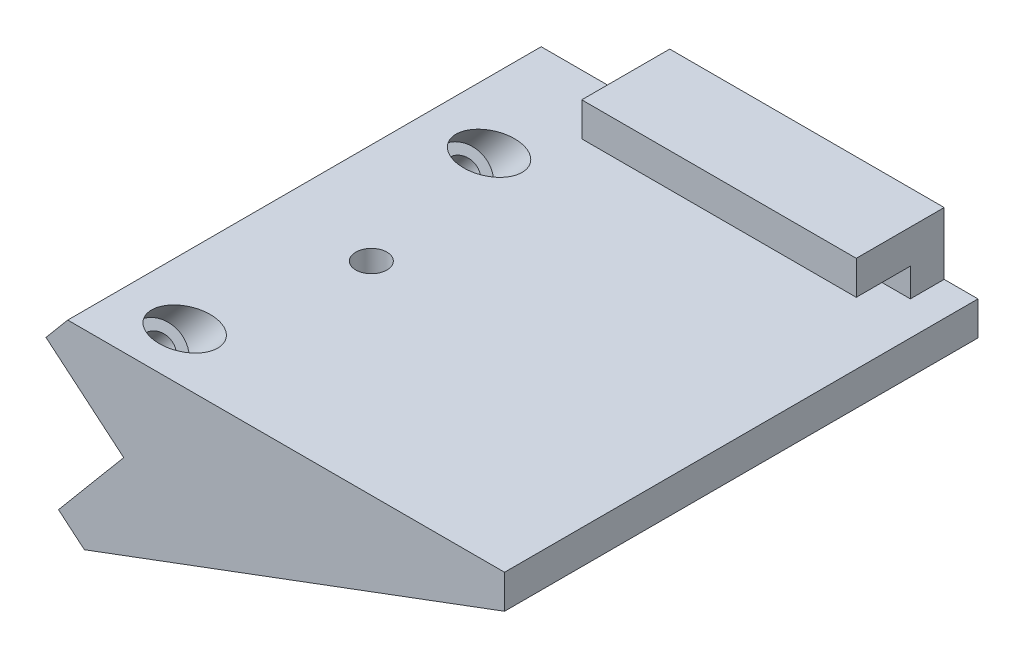
from build123d import *

# Parameters (mm, degrees)
EXTRUDE_1_DEPTH     = 65
SKETCH_4_R          = 2.25
CUT_EXTRUDE_2_DEPTH = 44
CUT_EXTRUDE_START   = -5
SKETCH_5_R          = 3.75
CUT_EXTRUDE_3_DEPTH = 44
EXTRUDE_2_DEPTH     = 5
EXTRUDE_4_DEPTH     = 8
SKETCH_9_R          = 2.3
CUT_EXTRUDE_4_DEPTH = 3.5
CUT_EXTRUDE_6_DEPTH = 14
CUT_EXTRUDE_7_DEPTH = 5


with BuildPart() as part:
    # ｽｹｯﾁ1 → ﾎﾞｽ - 押し出し1 (new body)
    with BuildSketch(Plane.XY):
        Polygon((0, 0), (9.641814145, 11.490666647), (-1.848852501, 21.132480792), (1.365085547, 24.962703008), (65.946194887, 24.962703008), (65.946194887, 19.962703008), (3.830222216, -3.213938048), align=None)
    extrude(amount=EXTRUDE_1_DEPTH)

    # ｽｹｯﾁ4 → ｶｯﾄ - 押し出し2 (cut)
    with BuildSketch(Plane(origin=(9.641814145, 11.490666647, 0), x_dir=(-0.766044443, 0.64278761, 0), z_dir=(-0.64278761, -0.766044443, 0))):
        with Locations((7.5, -12.5)):
            Circle(SKETCH_4_R)
        with Locations((7.5, -57.5)):
            Circle(SKETCH_4_R)
    extrude(amount=-CUT_EXTRUDE_2_DEPTH, mode=Mode.SUBTRACT)

    # ｽｹｯﾁ5 → ｶｯﾄ - 押し出し3 (cut)
    with BuildSketch(Plane(origin=(9.641814145, 11.490666647, 0), x_dir=(-0.766044443, 0.64278761, 0), z_dir=(-0.64278761, -0.766044443, 0)).offset(CUT_EXTRUDE_START)):
        with Locations((7.5, -57.5)):
            Circle(SKETCH_5_R)
        with Locations((7.5, -12.5)):
            Circle(SKETCH_5_R)
    extrude(amount=-CUT_EXTRUDE_3_DEPTH, mode=Mode.SUBTRACT)

    # ｽｹｯﾁ6 → ﾎﾞｽ - 押し出し2 (add)
    with BuildSketch(Plane.XY):
        Polygon((0, 0), (3.830222216, -3.213938048), (65.946194887, 19.962703008), (65.946194887, 34.162703008), (9.084802154, 34.162703008), (-1.848852501, 21.132480792), (9.641814145, 11.490666647), align=None)
    extrude(amount=-EXTRUDE_2_DEPTH)

    # ｽｹｯﾁ8 → ﾎﾞｽ - 押し出し4 (add)
    with BuildSketch(Plane.XY):
        Polygon((65.946194887, 34.162703008), (65.946194887, 29.162703008), (4.889303998, 29.162703008), (9.084802154, 34.162703008), align=None)
    extrude(amount=EXTRUDE_4_DEPTH)

    # ｽｹｯﾁ9 → ｶｯﾄ - 押し出し4 (cut)
    with BuildSketch(Plane(origin=(0, 24.962703008, 0), x_dir=(1, 0, 0), z_dir=(0, 1, 0))):
        with Locations((16.255085547, -35)):
            Circle(SKETCH_9_R)
    extrude(amount=-CUT_EXTRUDE_4_DEPTH, mode=Mode.SUBTRACT)

    # ｽｹｯﾁ11 → ｶｯﾄ - 押し出し6 (cut, through all)
    with BuildSketch(Plane.XY.offset(8)):
        Polygon((1.365085547, 24.962703008), (20.364802154, 24.962703008), (20.364802154, 34.162703008), (9.084802154, 34.162703008), align=None)
    extrude(amount=-CUT_EXTRUDE_6_DEPTH, mode=Mode.SUBTRACT)

    # ｽｹｯﾁ12 → ｶｯﾄ - 押し出し7 (cut)
    with BuildSketch(Plane(origin=(65.946194887, 0, 0), x_dir=(0, 0, -1), z_dir=(1, 0, 0))):
        Polygon((0, 24.962703008), (5, 24.962703008), (5, 34.162703008), (-8, 34.162703008), (-8, 29.162703008), (0, 29.162703008), align=None)
    extrude(amount=-CUT_EXTRUDE_7_DEPTH, mode=Mode.SUBTRACT)


solid = part.part
